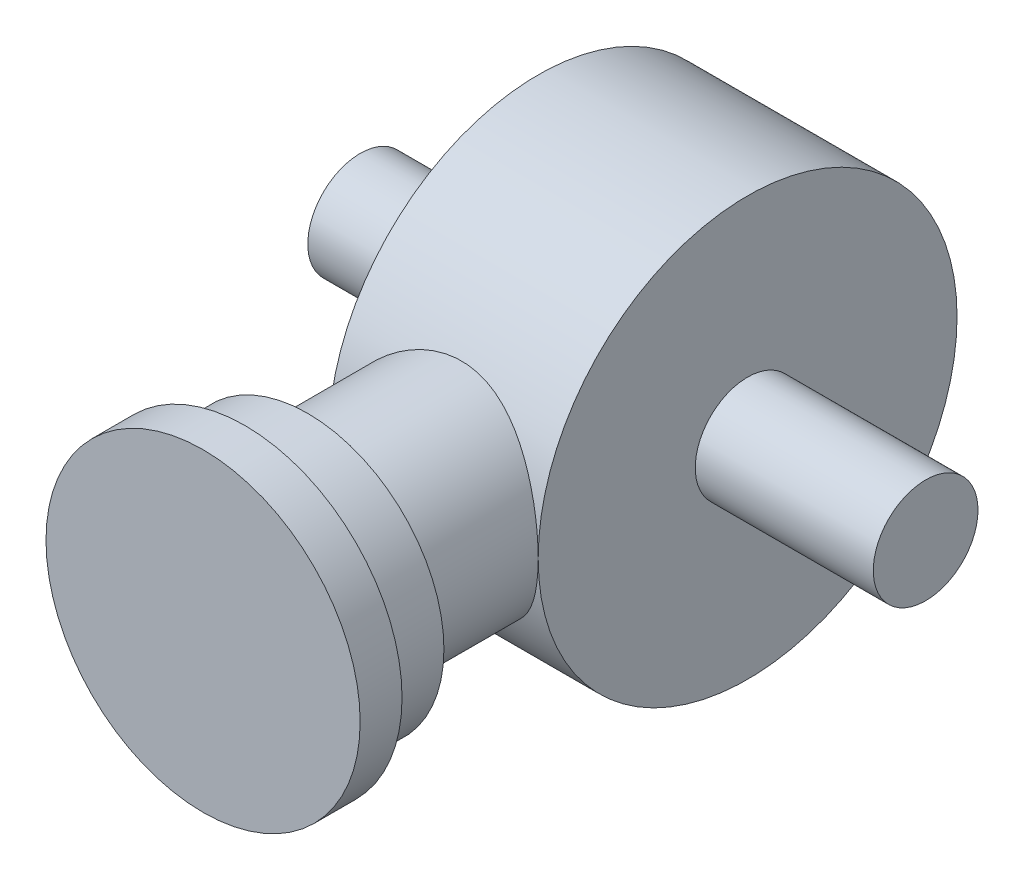
from build123d import *

# Parameters (mm, degrees)
CROQUIS1_R              = 25.4
SALIENTE_EXTRUIR1_DEPTH = 12.7
SALIENTE_EXTRUIR2_REACH = 68.04
CROQUIS2_R              = 12.7
CROQUIS3_R              = 16.51
SALIENTE_EXTRUIR3_DEPTH = 7.62
CROQUIS4_R              = 19.05
SALIENTE_EXTRUIR4_DEPTH = 5.08
CROQUIS6_R              = 6.35
SALIENTE_EXTRUIR5_DEPTH = 34.29


with BuildPart() as part:
    # Croquis1 → Saliente-Extruir1 (new body, symmetric)
    with BuildSketch(Plane(origin=(0, 0, 0), x_dir=(0, 0, -1), z_dir=(1, 0, 0))):
        Circle(CROQUIS1_R)
    extrude(amount=SALIENTE_EXTRUIR1_DEPTH, both=True)

    # Croquis2 → Saliente-Extruir2 (add, up to next)
    with BuildSketch(Plane.XY.offset(40.64), mode=Mode.PRIVATE) as saliente_extruir2_sk1:
        Circle(CROQUIS2_R)
    saliente_extruir2_tool1 = extrude(saliente_extruir2_sk1.sketch, amount=-SALIENTE_EXTRUIR2_REACH, mode=Mode.PRIVATE) - part.part
    add(saliente_extruir2_tool1.solids().sort_by_distance((0, 0, 40.64))[0])

    # Croquis3 → Saliente-Extruir3 (add)
    with BuildSketch(Plane.XY.offset(40.64)):
        Circle(CROQUIS3_R)
    extrude(amount=SALIENTE_EXTRUIR3_DEPTH)

    # Croquis4 → Saliente-Extruir4 (add)
    with BuildSketch(Plane.XY.offset(48.26)):
        Circle(CROQUIS4_R)
    extrude(amount=SALIENTE_EXTRUIR4_DEPTH)

    # Croquis6 → Saliente-Extruir5 (add, symmetric)
    with BuildSketch(Plane(origin=(0, 0, 0), x_dir=(0, 0, -1), z_dir=(1, 0, 0))):
        Circle(CROQUIS6_R)
    extrude(amount=SALIENTE_EXTRUIR5_DEPTH, both=True)


solid = part.part
